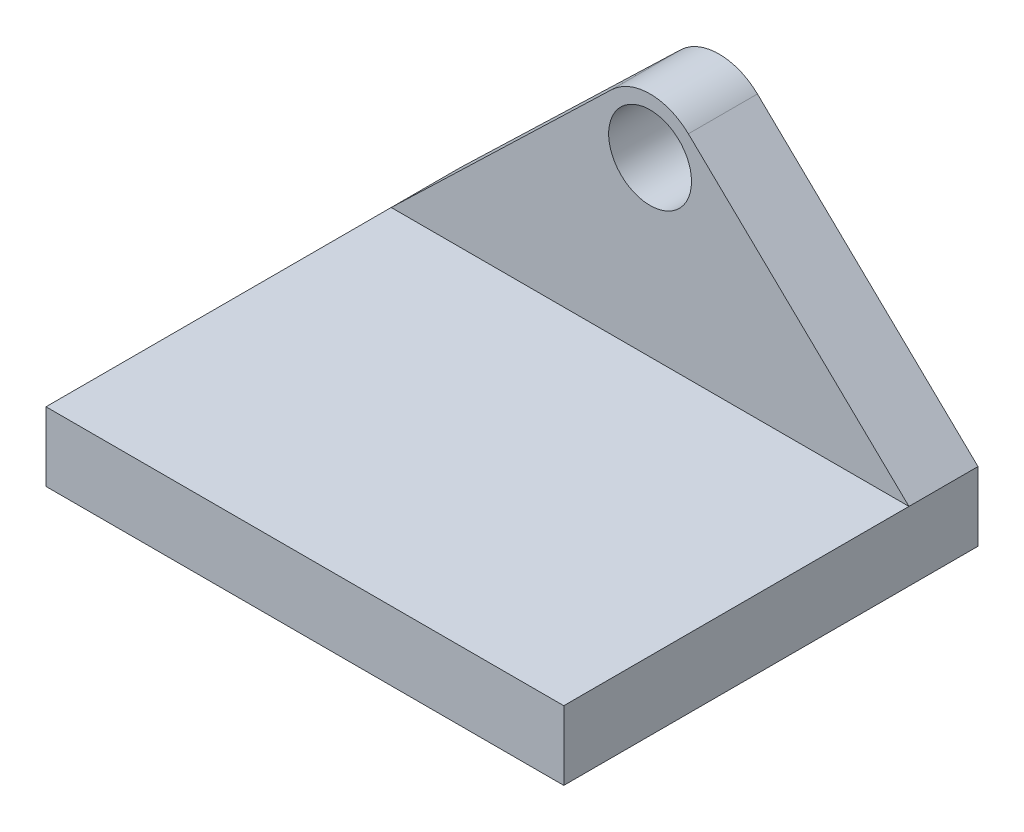
from build123d import *

# Parameters (mm, degrees)
SKETCH2_R           = 6
BOSS_EXTRUDE1_DEPTH = 10
SKETCH3_W           = 75
SKETCH3_H           = 10
BOSS_EXTRUDE2_DEPTH = 60
SKETCH4_R           = 2.25
CUT_EXTRUDE1_DEPTH  = 9
SKETCH5_W           = 10
SKETCH5_H           = 10
CUT_EXTRUDE2_DEPTH  = 2.5


with BuildPart() as part:
    # Sketch2 → Boss-Extrude1 (new body)
    with BuildSketch(Plane.XY):
        with BuildLine():
            Line((-37.5, -5), (37.5, -5))
            Line((37.5, -5), (37.5, 5))
            Line((37.5, 5), (5.548671219, 35.763006828))
            ThreePointArc((5.548671219, 35.763006828), (0, 38), (-5.548671219, 35.763006828))
            Line((-5.548671219, 35.763006828), (-37.5, 5))
            Line((-37.5, 5), (-37.5, -5))
        make_face()
        with Locations((0, 30)):
            Circle(SKETCH2_R, mode=Mode.SUBTRACT)
    extrude(amount=BOSS_EXTRUDE1_DEPTH)

    # Sketch3 → Boss-Extrude2 (add)
    with BuildSketch(Plane.XY):
        Rectangle(SKETCH3_W, SKETCH3_H)
    extrude(amount=BOSS_EXTRUDE2_DEPTH)

    # Sketch4 → Cut-Extrude1 (cut)
    with BuildSketch(Plane.XZ.offset(5)):
        with Locations((27.5, 5)):
            Circle(SKETCH4_R)
        with Locations((12.5, 5)):
            Circle(SKETCH4_R)
        with Locations((-12.5, 5)):
            Circle(SKETCH4_R)
        with Locations((-27.5, 5)):
            Circle(SKETCH4_R)
    extrude(amount=-CUT_EXTRUDE1_DEPTH, mode=Mode.SUBTRACT)

    # Sketch5 → Cut-Extrude2 (cut)
    with BuildSketch(Plane(origin=(0, 0, 0), x_dir=(-1, 0, 0), z_dir=(0, 0, -1))):
        with Locations((-10, 5)):
            Rectangle(SKETCH5_W, SKETCH5_H)
        with Locations((10, 5)):
            Rectangle(SKETCH5_W, SKETCH5_H)
    extrude(amount=-CUT_EXTRUDE2_DEPTH, mode=Mode.SUBTRACT)


solid = part.part
